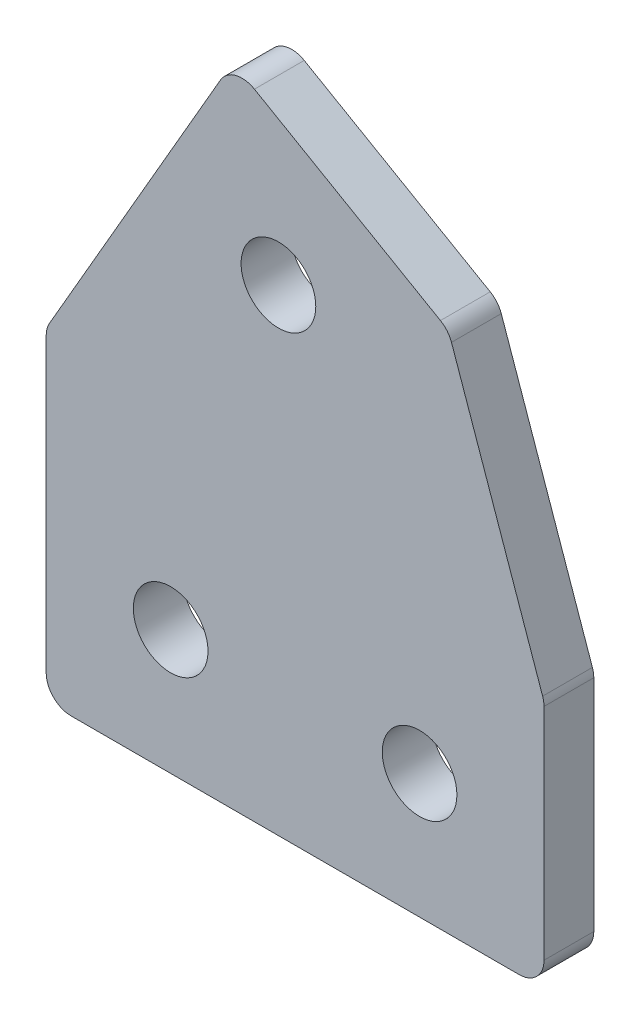
from build123d import *

# Parameters (mm, degrees)
SKETCH_1_R      = 1.5
EXTRUDE_1_DEPTH = 2
FILLET_1_R      = 1


with BuildPart() as part:
    # 草图1 → 凸台-拉伸1 (new body)
    with BuildSketch(Plane.XY):
        Polygon((-133.240644315, -50.984206154), (-133.240644315, -37.984206154), (-125.740644315, -24.993825098), (-117.080390278, -29.993825098), (-113.240644315, -40.984206154), (-113.240644315, -50.984206154), (-123.240644315, -50.984206154), align=None)
        with Locations((-128.240644315, -45.984206154)):
            Circle(SKETCH_1_R, mode=Mode.SUBTRACT)
        with Locations((-123.910517296, -31.823952117)):
            Circle(SKETCH_1_R, mode=Mode.SUBTRACT)
        with Locations((-118.240644315, -45.984206154)):
            Circle(SKETCH_1_R, mode=Mode.SUBTRACT)
    extrude(amount=EXTRUDE_1_DEPTH)

    # 圆角1
    fillet_1_edges = [part.edges().sort_by_distance(p)[0] for p in [
        (-133.240644315, -50.984206154, 1),
        (-133.240644315, -37.984206154, 1),
        (-125.740644315, -24.993825098, 1),
        (-117.080390278, -29.993825098, 1),
        (-113.240644315, -40.984206154, 1),
        (-113.240644315, -50.984206154, 1),
    ]]
    fillet(fillet_1_edges, radius=FILLET_1_R)


solid = part.part
